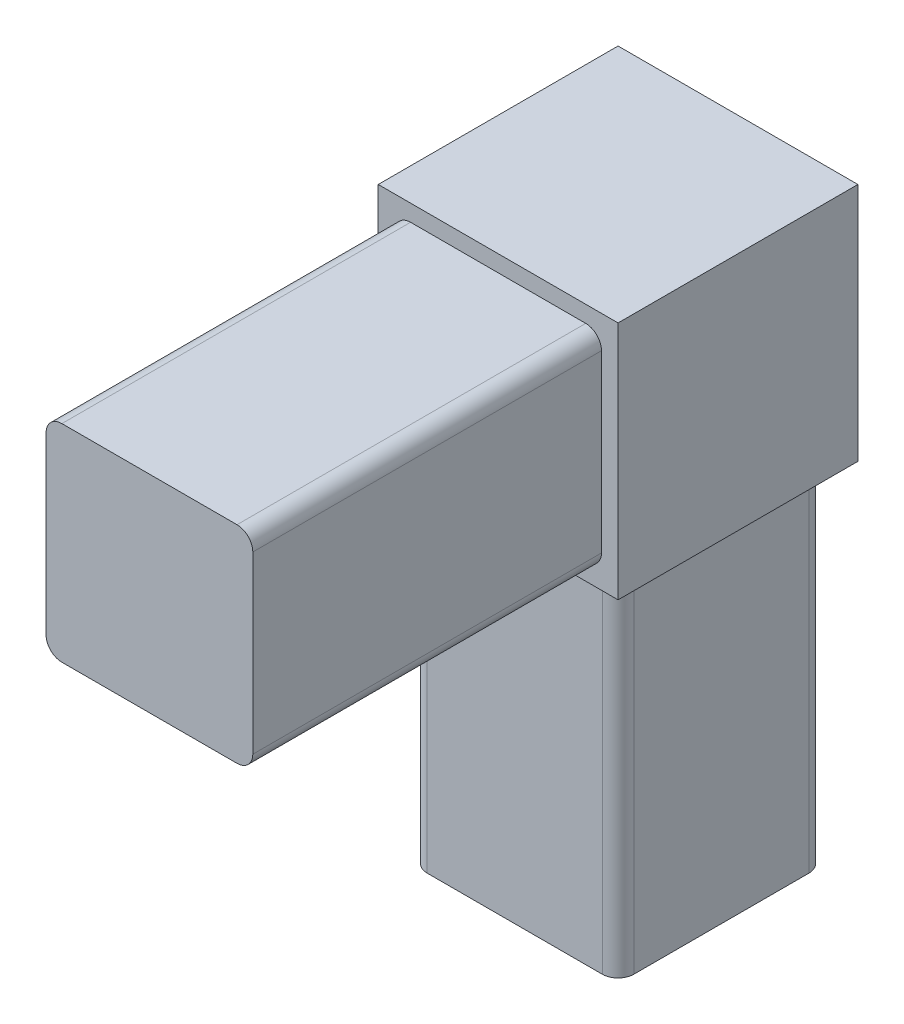
from build123d import *

# Parameters (mm, degrees)
SKETCH1_W           = 16.637
SKETCH1_H           = 16.637
BOSS_EXTRUDE1_DEPTH = 28.067
SKETCH2_W           = 19.304
SKETCH2_H           = 19.304
BOSS_EXTRUDE2_DEPTH = 19.304
SKETCH3_W           = 16.637
SKETCH3_H           = 16.637
BOSS_EXTRUDE3_DEPTH = 28.067
FILLET1_R           = 1.27


with BuildPart() as part:
    # Sketch1 → Boss-Extrude1 (new body)
    with BuildSketch(Plane(origin=(0, 0, 0), x_dir=(1, 0, 0), z_dir=(0, 1, 0))):
        Rectangle(SKETCH1_W, SKETCH1_H)
    extrude(amount=BOSS_EXTRUDE1_DEPTH)

    # Sketch2 → Boss-Extrude2 (add)
    with BuildSketch(Plane(origin=(0, 28.067, 0), x_dir=(1, 0, 0), z_dir=(0, 1, 0))):
        Rectangle(SKETCH2_W, SKETCH2_H)
    extrude(amount=BOSS_EXTRUDE2_DEPTH)

    # Sketch3 → Boss-Extrude3 (add)
    with BuildSketch(Plane.XY.offset(9.652)):
        with Locations((0, 37.719)):
            Rectangle(SKETCH3_W, SKETCH3_H)
    extrude(amount=BOSS_EXTRUDE3_DEPTH)

    # Fillet1
    fillet1_edges = [part.edges().sort_by_distance(p)[0] for p in [
        (8.3185, 29.4005, 23.6855),
        (8.3185, 46.0375, 23.6855),
        (-8.3185, 46.0375, 23.6855),
        (-8.3185, 29.4005, 23.6855),
        (8.3185, 14.0335, 8.3185),
        (-8.3185, 14.0335, 8.3185),
        (-8.3185, 14.0335, -8.3185),
        (8.3185, 14.0335, -8.3185),
    ]]
    fillet(fillet1_edges, radius=FILLET1_R)


solid = part.part
